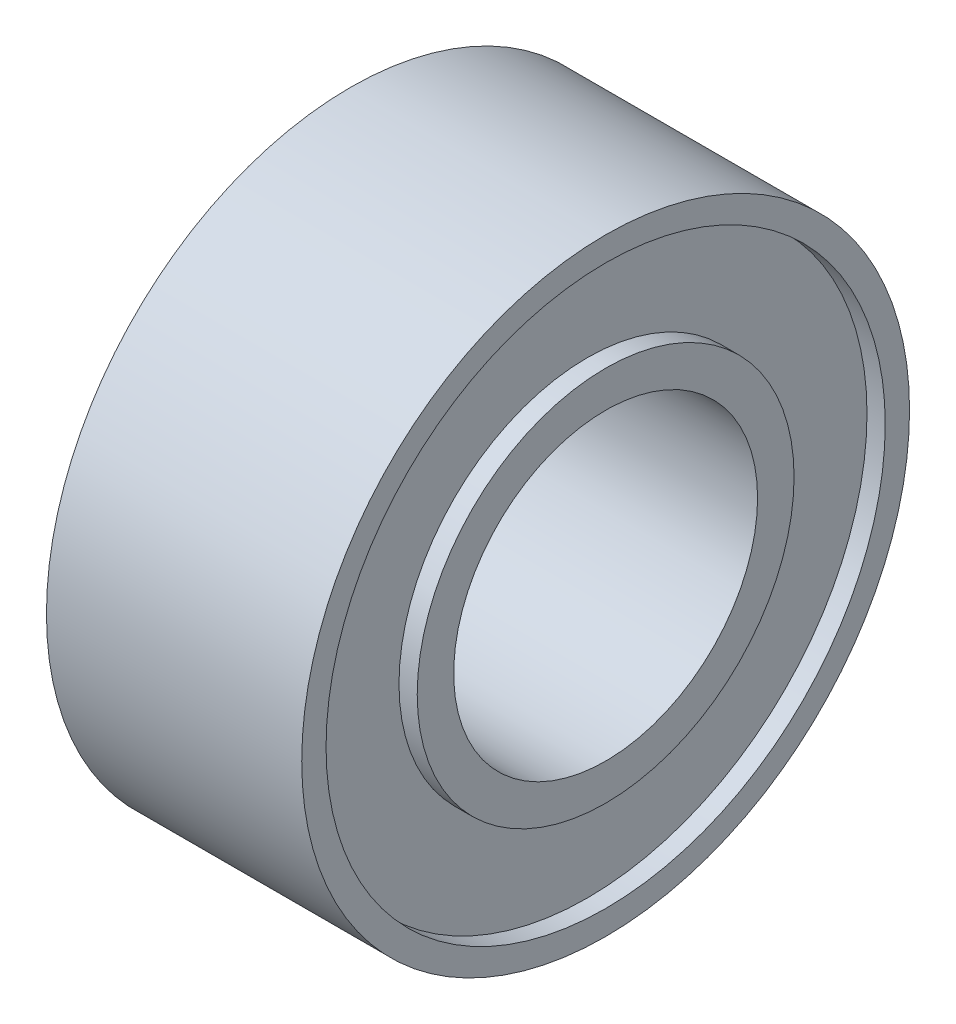
from build123d import *


with BuildPart() as part:
    # Sketch1 → Revolve1 (revolve)
    with BuildSketch(Plane.XY):
        Polygon((2.1, 2.5), (-2.1, 2.5), (-2.1, 3.1), (-1.8, 3.1), (-1.8, 4.6), (-2.1, 4.6), (-2.1, 5), (2.1, 5), (2.1, 4.6), (1.8, 4.6), (1.8, 3.1), (2.1, 3.1), align=None)
    revolve(axis=Axis((0, 0, 0), (-1, 0, 0)))


solid = part.part
